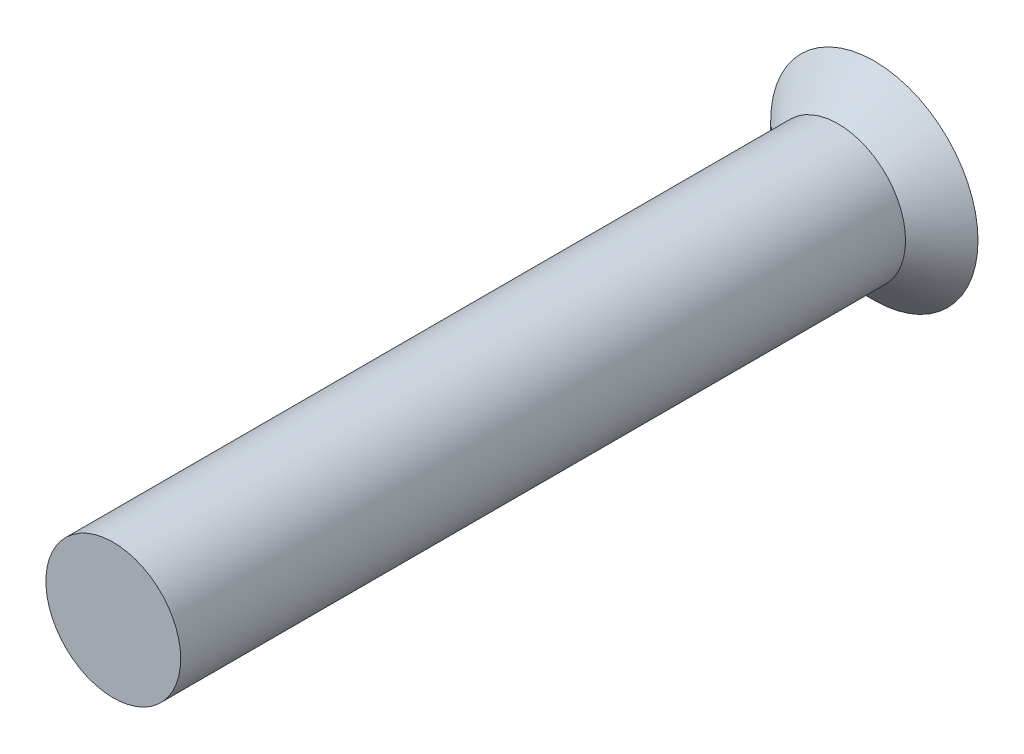
from build123d import *

# Parameters (mm, degrees)
SKETCH1_R           = 0.465
BOSS_EXTRUDE1_DEPTH = 2.5
CUT_EXTRUDE1_DEPTH  = 0.1


with BuildPart() as part:
    # Sketch1 → Boss-Extrude1 (new body, symmetric)
    with BuildSketch(Plane.XY):
        Circle(SKETCH1_R)
    extrude(amount=BOSS_EXTRUDE1_DEPTH, both=True)

    # Sketch2 → Revolve1 (revolve)
    with BuildSketch(Plane(origin=(0, 0, 0), x_dir=(0, 0, -1), z_dir=(1, 0, 0))):
        Polygon((2.75, 0.715), (2.75, 0), (2.5, 0), (2.5, 0.465), align=None)
    revolve(axis=Axis((0, 0, 2.0805), (0, 0, -1)))

    # Sketch3 → Cut-Extrude1 (cut)
    with BuildSketch(Plane(origin=(0, 0, -2.75), x_dir=(-1, 0, 0), z_dir=(0, 0, -1))):
        Polygon((0.1, 0.6), (-0.1, 0.6), (-0.1, 0.1), (-0.6, 0.1), (-0.6, -0.1), (-0.1, -0.1), (-0.1, -0.6), (0.1, -0.6), (0.1, -0.1), (0.6, -0.1), (0.6, 0.1), (0.1, 0.1), align=None)
    extrude(amount=-CUT_EXTRUDE1_DEPTH, mode=Mode.SUBTRACT)


solid = part.part
